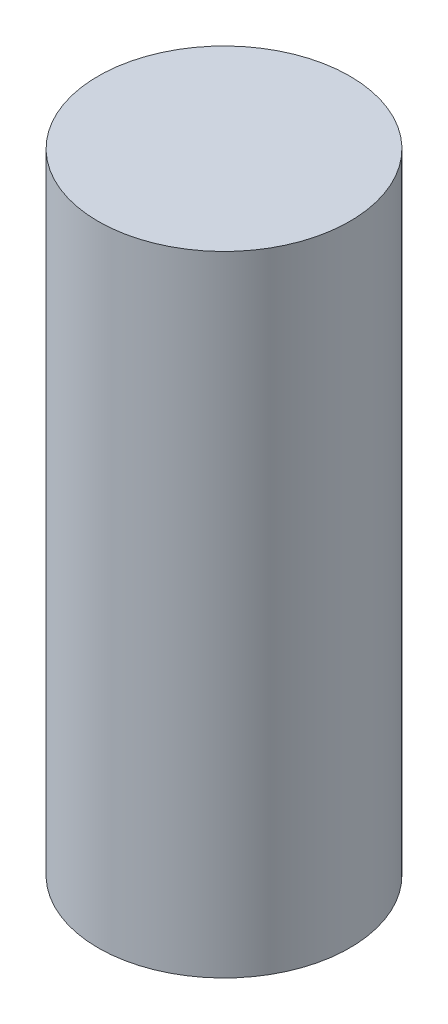
from build123d import *

# Parameters (mm, degrees)
SKETCH1_R                   = 25.4
BOSS_EXTRUDE1_DEPTH         = 127
F_1_4_20_TAPPED_HOLE1_D     = 5.1054
F_1_4_20_TAPPED_HOLE1_DEPTH = 25.4
F_1_4_20_TAPPED_HOLE1_TIP   = 1.533816902


with BuildPart() as part:
    # Sketch1 → Boss-Extrude1 (new body)
    with BuildSketch(Plane(origin=(0, 0, 0), x_dir=(1, 0, 0), z_dir=(0, 1, 0))):
        Circle(SKETCH1_R)
    extrude(amount=BOSS_EXTRUDE1_DEPTH)

    # 1/4-20 Tapped Hole1
    with Locations(Plane(origin=(0, 0, 0), x_dir=(-1, 0, 0), z_dir=(0, -1, 0))):
        with Locations((12.7, 0), (-12.7, 0)):
            Hole(F_1_4_20_TAPPED_HOLE1_D / 2, depth=F_1_4_20_TAPPED_HOLE1_DEPTH)
            with Locations((0, 0, -(F_1_4_20_TAPPED_HOLE1_DEPTH + F_1_4_20_TAPPED_HOLE1_TIP / 2))):  # 118° drill point
                Cone(0, F_1_4_20_TAPPED_HOLE1_D / 2, F_1_4_20_TAPPED_HOLE1_TIP, mode=Mode.SUBTRACT)


solid = part.part
